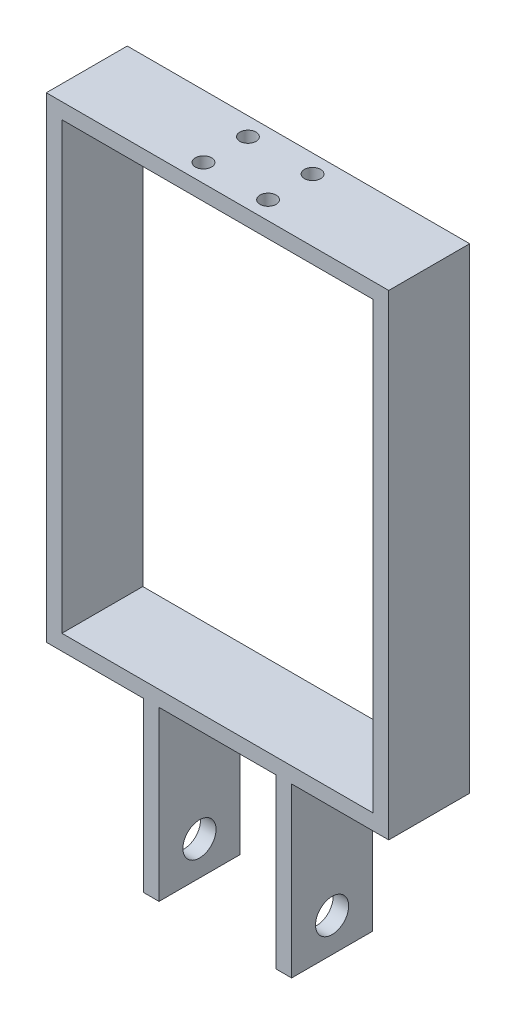
from build123d import *

# Parameters (mm, degrees)
SKETCH1_W           = 63.5
SKETCH1_H           = 90.7288
BOSS_EXTRUDE1_DEPTH = 16.51
SKETCH2_R           = 3.3782
CUT_EXTRUDE1_DEPTH  = 42.672
SKETCH3_R           = 1.65
CUT_EXTRUDE2_DEPTH  = 42.672


with BuildPart() as part:
    # Sketch1 → Boss-Extrude1 (new body)
    with BuildSketch(Plane.XY):
        Polygon((3.175, 34.29), (27.051, 34.29), (27.051, 0), (30.226, 0), (30.226, 34.29), (50.038, 34.29), (50.038, 131.3688), (-19.812, 131.3688), (-19.812, 34.29), (0, 34.29), (0, 0), (3.175, 0), align=None)
        with Locations((15.113, 82.8294)):
            Rectangle(SKETCH1_W, SKETCH1_H, mode=Mode.SUBTRACT)
    extrude(amount=BOSS_EXTRUDE1_DEPTH)

    # Sketch2 → Cut-Extrude1 (cut)
    with BuildSketch(Plane.ZY):
        with Locations((8.255, 6.9215)):
            Circle(SKETCH2_R)
    extrude(amount=-CUT_EXTRUDE1_DEPTH, mode=Mode.SUBTRACT)

    # Sketch3 → Cut-Extrude2 (cut)
    with BuildSketch(Plane(origin=(0, 131.3688, 0), x_dir=(1, 0, 0), z_dir=(0, 1, 0))):
        with Locations((8.52383023, -3.718168314)):
            Circle(SKETCH3_R)
        with Locations((8.52383023, -12.791831686)):
            Circle(SKETCH3_R)
        with Locations((21.70216977, -12.791831686)):
            Circle(SKETCH3_R)
        with Locations((21.70216977, -3.718168314)):
            Circle(SKETCH3_R)
    extrude(amount=-CUT_EXTRUDE2_DEPTH, mode=Mode.SUBTRACT)


solid = part.part
